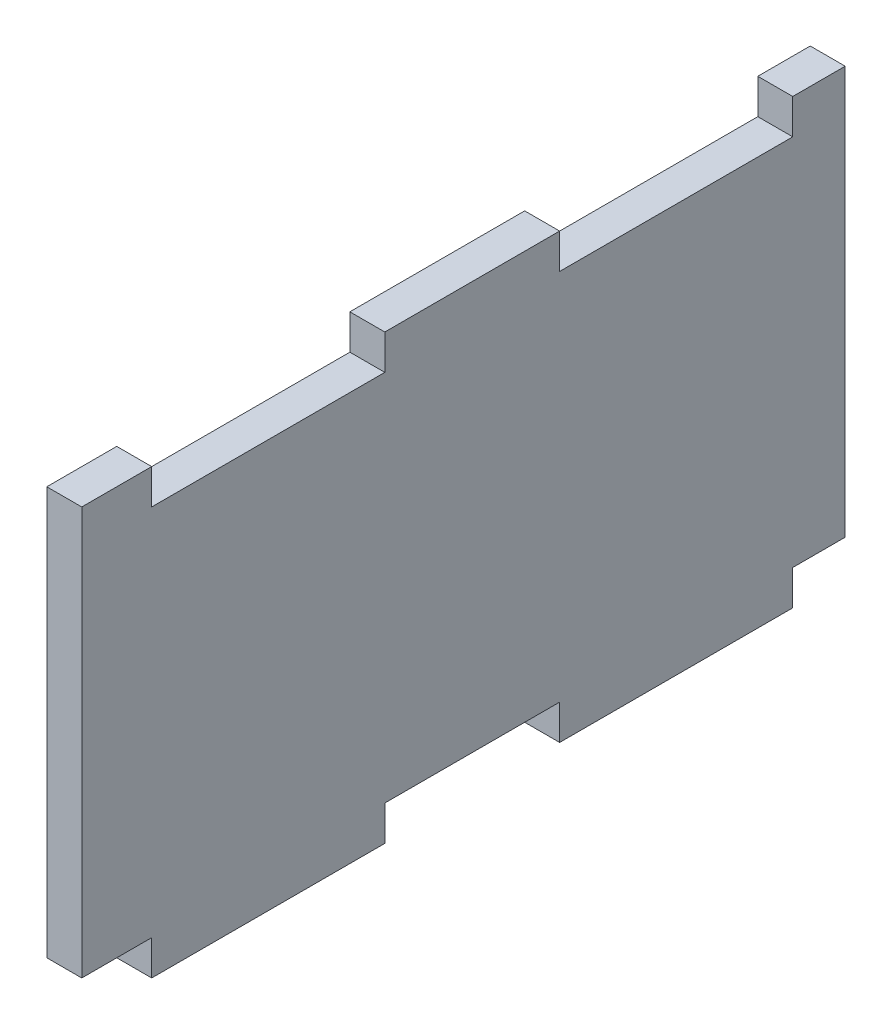
from build123d import *

# Parameters (mm, degrees)
BOSS_EXTRUDE1_DEPTH = 3
SKETCH2_W           = 211.5
SKETCH2_H           = 45
CUT_EXTRUDE1_DEPTH  = 10


with BuildPart() as part:
    # Sketch1 → Boss-Extrude1 (new body)
    with BuildSketch(Plane(origin=(0, 0, 0), x_dir=(0, 0, -1), z_dir=(1, 0, 0))):
        Polygon((26, 0), (41, 0), (41, -3), (61, -3), (61, 0), (76, 0), (76, -3), (96, -3), (96, 0), (111, 0), (111, -3), (131, -3), (131, 0), (146, 0), (146, -3), (166, -3), (166, 0), (181, 0), (181, -3), (201, -3), (201, 0), (216, 0), (216, -3), (236, -3), (236, 0), (251, 0), (251, -3), (271, -3), (271, 0), (277, 0), (277, 35), (271, 35), (271, 32), (251, 32), (251, 35), (236, 35), (236, 32), (216, 32), (216, 35), (201, 35), (201, 32), (181, 32), (181, 35), (166, 35), (166, 32), (146, 32), (146, 35), (131, 35), (131, 32), (111, 32), (111, 35), (96, 35), (96, 32), (76, 32), (76, 35), (61, 35), (61, 32), (41, 32), (41, 35), (26, 35), (26, 32), (6, 32), (6, 35), (0, 35), (0, 0), (6, 0), (6, -3), (26, -3), align=None)
    extrude(amount=BOSS_EXTRUDE1_DEPTH)

    # Sketch2 → Cut-Extrude1 (cut)
    with BuildSketch(Plane(origin=(3, 0, 0), x_dir=(0, 0, -1), z_dir=(1, 0, 0))):
        with Locations((171.25, 17.5)):
            Rectangle(SKETCH2_W, SKETCH2_H)
    extrude(amount=-CUT_EXTRUDE1_DEPTH, mode=Mode.SUBTRACT)


solid = part.part
